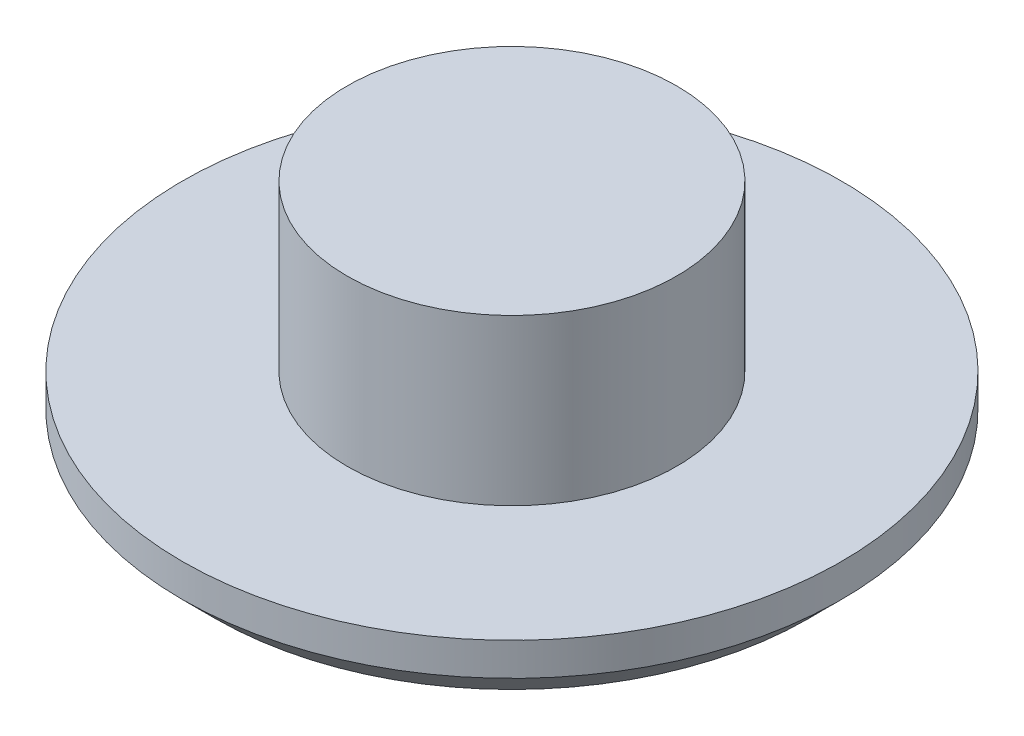
from build123d import *

# Parameters (mm, degrees)
SKETCH1_R           = 12.7
BOSS_EXTRUDE1_DEPTH = 2.54
SKETCH2_R           = 6.35
BOSS_EXTRUDE2_DEPTH = 6.35
CHAMFER1_SIZE       = 1.27


with BuildPart() as part:
    # Sketch1 → Boss-Extrude1 (new body)
    with BuildSketch(Plane(origin=(0, 0, 0), x_dir=(1, 0, 0), z_dir=(0, 1, 0))):
        Circle(SKETCH1_R)
    extrude(amount=BOSS_EXTRUDE1_DEPTH)

    # Sketch2 → Boss-Extrude2 (add)
    with BuildSketch(Plane(origin=(0, 2.54, 0), x_dir=(1, 0, 0), z_dir=(0, 1, 0))):
        Circle(SKETCH2_R)
    extrude(amount=BOSS_EXTRUDE2_DEPTH)

    # Chamfer1
    chamfer1_edges = [part.edges().sort_by_distance(p)[0] for p in [
        (-12.7, 0, 0),
    ]]
    chamfer(chamfer1_edges, length=CHAMFER1_SIZE)


solid = part.part
